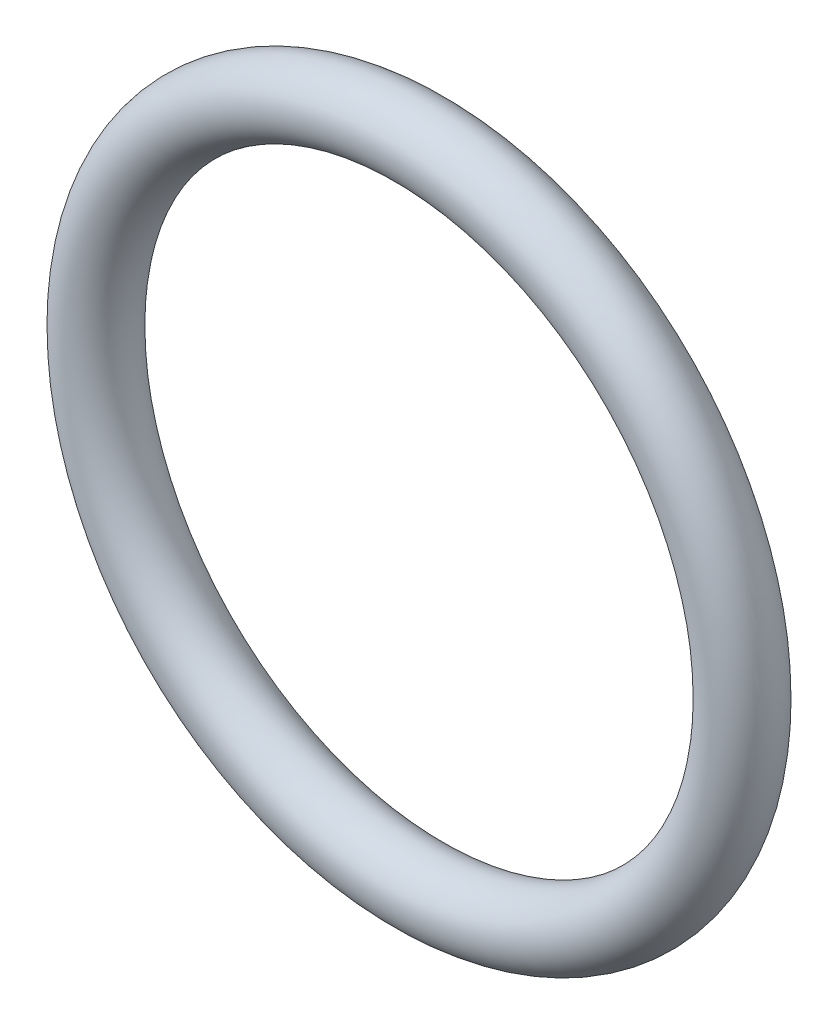
from build123d import *

# Parameters (mm, degrees)
SKETCH2_R = 1.5


with BuildPart() as part:
    # Sketch2 → Revolve1 (revolve)
    with BuildSketch(Plane(origin=(0, 0, 0), x_dir=(1, 0, 0), z_dir=(0, 1, 0))):
        with Locations((14, 0)):
            Circle(SKETCH2_R)
    revolve(axis=Axis((0, 0, 6.25), (0, 0, -1)))


solid = part.part
